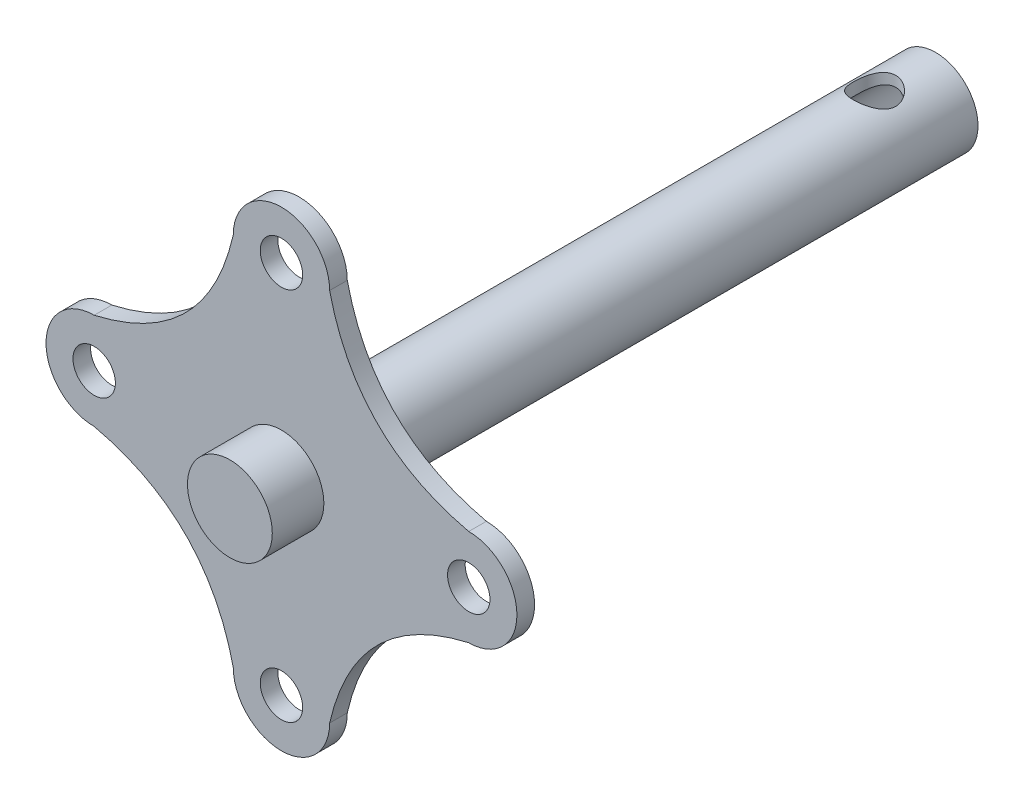
from build123d import *

# Parameters (mm, degrees)
SKETCH1_R           = 3.96875
BOSS_EXTRUDE1_DEPTH = 3.302
SKETCH2_R           = 7.9375
BOSS_EXTRUDE2_DEPTH = 9.652
SKETCH3_R           = 7.9375
BOSS_EXTRUDE3_DEPTH = 119.126
SKETCH4_R           = 6
CUT_EXTRUDE1_DEPTH  = 25.4
CUT_EXTRUDE2_REACH  = 56.229
SKETCH5_R           = 3.96875


with BuildPart() as part:
    # Sketch1 → Boss-Extrude1 (new body)
    with BuildSketch(Plane.XY):
        with BuildLine():
            ThreePointArc((9.017, 35.052), (0, 44.069), (-9.017, 35.052))
            add(Edge.make_bspline(
                [(-9.017, 35.052), (-13.886524484, 13.886524484), (-35.052, 9.017)],
                knots=[0, 0, 0, 1, 1, 1], degree=2))
            ThreePointArc((-35.052, 9.017), (-44.069, 0), (-35.052, -9.017))
            add(Edge.make_bspline(
                [(-35.052, -9.017), (-13.886524484, -13.886524484), (-9.017, -35.052)],
                knots=[0, 0, 0, 1, 1, 1], degree=2))
            ThreePointArc((-9.017, -35.052), (0, -44.069), (9.017, -35.052))
            add(Edge.make_bspline(
                [(35.052, -9.017), (13.886524484, -13.886524484), (9.017, -35.052)],
                knots=[0, 0, 0, 1, 1, 1], degree=2))
            ThreePointArc((35.052, -9.017), (44.069, 0), (35.052, 9.017))
            add(Edge.make_bspline(
                [(9.017, 35.052), (13.886524484, 13.886524484), (35.052, 9.017)],
                knots=[0, 0, 0, 1, 1, 1], degree=2))
        make_face()
        with Locations((0, 35.052)):
            Circle(SKETCH1_R, mode=Mode.SUBTRACT)
        with Locations((35.052, 0)):
            Circle(SKETCH1_R, mode=Mode.SUBTRACT)
        with Locations((0, -35.052)):
            Circle(SKETCH1_R, mode=Mode.SUBTRACT)
        with Locations((-35.052, 0)):
            Circle(SKETCH1_R, mode=Mode.SUBTRACT)
    extrude(amount=BOSS_EXTRUDE1_DEPTH)

    # Sketch2 → Boss-Extrude2 (add)
    with BuildSketch(Plane.XY.offset(3.302)):
        Circle(SKETCH2_R)
    extrude(amount=BOSS_EXTRUDE2_DEPTH)

    # Sketch3 → Boss-Extrude3 (add)
    with BuildSketch(Plane(origin=(0, 0, 0), x_dir=(-1, 0, 0), z_dir=(0, 0, -1))):
        Circle(SKETCH3_R)
    extrude(amount=BOSS_EXTRUDE3_DEPTH)

    # Sketch4 → Cut-Extrude1 (cut)
    with BuildSketch(Plane(origin=(0, 0, -119.126), x_dir=(-1, 0, 0), z_dir=(0, 0, -1))):
        Circle(SKETCH4_R)
    extrude(amount=-CUT_EXTRUDE1_DEPTH, mode=Mode.SUBTRACT)

    # Sketch5 → Cut-Extrude2 (cut, up to next)
    with BuildSketch(Plane(origin=(0, 10.16, 0), x_dir=(1, 0, 0), z_dir=(0, 1, 0)), mode=Mode.PRIVATE) as cut_extrude2_sk1:
        with Locations((0, 107.696)):
            Circle(SKETCH5_R)
    cut_extrude2_tool1 = extrude(cut_extrude2_sk1.sketch, amount=-CUT_EXTRUDE2_REACH, mode=Mode.PRIVATE) & part.part
    add(cut_extrude2_tool1.solids().sort_by_distance((0, 10.16, -107.696))[0], mode=Mode.SUBTRACT)


solid = part.part
